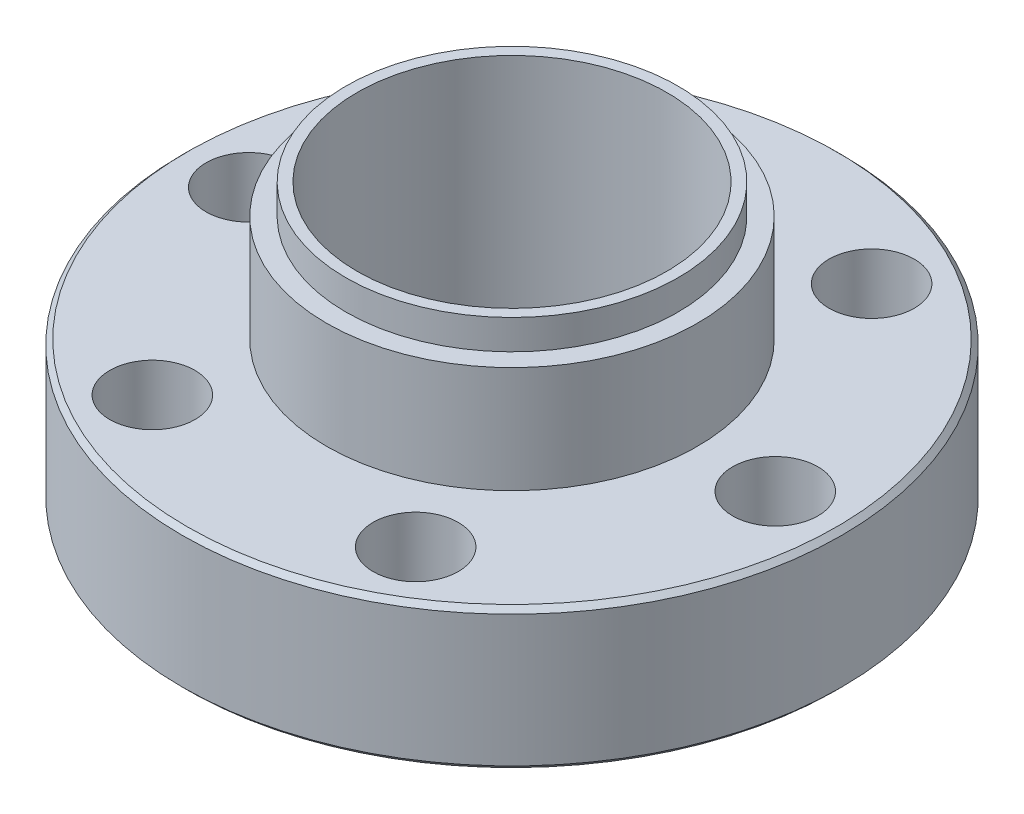
from build123d import *

# Parameters (mm, degrees)
SKETCH2_R                = 9.4996
BOSS_EXTRUDE1_DEPTH      = 5.461
SKETCH3_R                = 8.509
BOSS_EXTRUDE2_DEPTH      = 1.524
M13_CLEARANCE_HOLE1_D    = 15.875
M4_CLEARANCE_HOLE1_D     = 4.3688
M4_CLEARANCE_HOLE1_DEPTH = 14.224
CHAMFER1_SIZE            = 0.254


with BuildPart() as part:
    # Sketch1 → Revolve1 (revolve)
    with BuildSketch(Plane(origin=(0, 0, 0), x_dir=(-1, 0, 0), z_dir=(0, 0, -1))):
        Polygon((-9.144, 1.2954), (0, 1.2954), (0, 7.239), (-16.637, 7.239), (-16.891, 6.985), (-16.891, 0), (-10.7188, 0), (-10.7188, 1.233580325), (-9.144, 0.6604), align=None)
    revolve(axis=Axis((0, 0, 0), (0, 1, 0)))

    # Sketch2 → Boss-Extrude1 (add)
    with BuildSketch(Plane(origin=(0, 7.239, 0), x_dir=(-1, 0, 0), z_dir=(0, 1, 0))):
        Circle(SKETCH2_R)
    extrude(amount=BOSS_EXTRUDE1_DEPTH)

    # Sketch3 → Boss-Extrude2 (add)
    with BuildSketch(Plane(origin=(0, 12.7, 0), x_dir=(-1, 0, 0), z_dir=(0, 1, 0))):
        Circle(SKETCH3_R)
    extrude(amount=BOSS_EXTRUDE2_DEPTH)

    # M13 Clearance Hole1 (through all)
    with Locations(Plane(origin=(0, 14.224, 0), x_dir=(1, 0, 0), z_dir=(0, 1, 0))):
        with Locations((0, 0)):
            Hole(M13_CLEARANCE_HOLE1_D / 2)

    # M4 Clearance Hole1
    with Locations(Plane(origin=(0, 0, 0), x_dir=(-1, 0, 0), z_dir=(0, -1, 0))):
        with Locations((-13.4874, 0), (-6.7437, -11.680431031), (6.7437, -11.680431031), (13.4874, 0), (6.7437, 11.680431031), (-6.7437, 11.680431031)):
            Hole(M4_CLEARANCE_HOLE1_D / 2, depth=M4_CLEARANCE_HOLE1_DEPTH)

    # Chamfer1
    chamfer1_edges = [part.edges().sort_by_distance(p)[0] for p in [
        (-16.891, 0, 0),
    ]]
    chamfer(chamfer1_edges, length=CHAMFER1_SIZE)


solid = part.part
